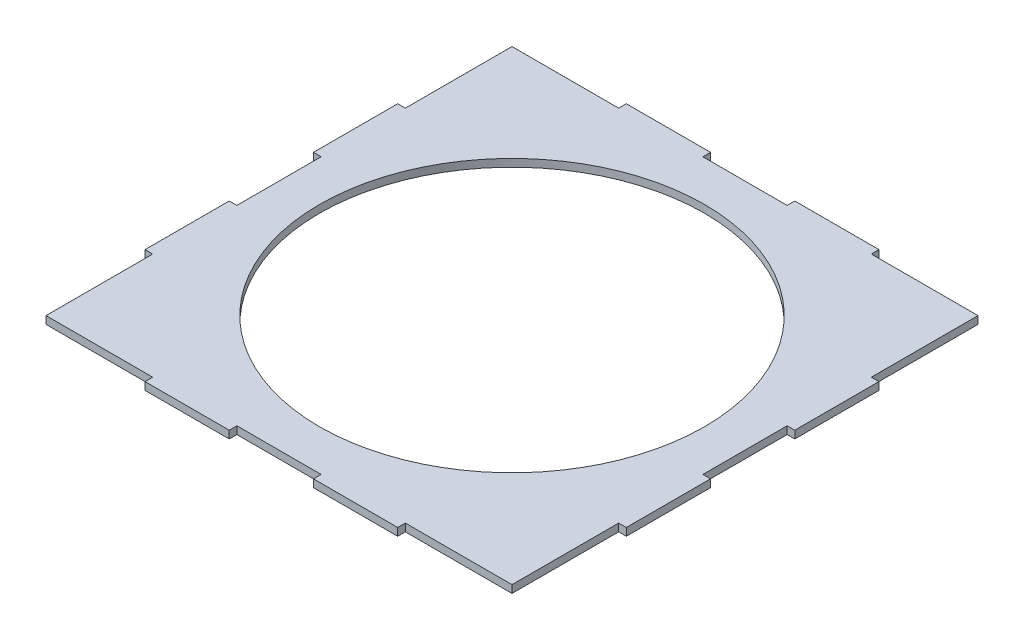
from build123d import *

# Parameters (mm, degrees)
ESQUISSE1_W             = 200
ESQUISSE1_H             = 200
BOSS_EXTRU_1_DEPTH      = 3.175
ESQUISSE2_W             = 3.175
ESQUISSE2_H             = 35
ESQUISSE2_H_2           = 47.5
ENL_V_MAT_EXTRU_1_DEPTH = 3.175
ESQUISSE4_W             = 44.325
ESQUISSE4_H             = 3.175
ESQUISSE4_W_2           = 35
ENL_V_MAT_EXTRU_3_DEPTH = 3.175
ESQUISSE3_R             = 80
ENL_V_MAT_EXTRU_2_DEPTH = 3.175


with BuildPart() as part:
    # Esquisse1 → Boss.-Extru.1 (new body)
    with BuildSketch(Plane(origin=(0, 0, 0), x_dir=(1, 0, 0), z_dir=(0, 1, 0))):
        Rectangle(ESQUISSE1_W, ESQUISSE1_H)
    extrude(amount=BOSS_EXTRU_1_DEPTH)

    # Esquisse2 → Enlèv. mat.-Extru.1 (cut)
    with BuildSketch(Plane(origin=(0, 3.175, 0), x_dir=(1, 0, 0), z_dir=(0, 1, 0))):
        with Locations((-98.4125, 0)):
            Rectangle(ESQUISSE2_W, ESQUISSE2_H)
        with Locations((-98.4125, 76.25)):
            Rectangle(ESQUISSE2_W, ESQUISSE2_H_2)
        with Locations((-98.4125, -76.25)):
            Rectangle(ESQUISSE2_W, ESQUISSE2_H_2)
    enl_v_mat_extru_1 = extrude(amount=-ENL_V_MAT_EXTRU_1_DEPTH, mode=Mode.SUBTRACT)

    # Symétrie1: Enlèv. mat.-Extru.1 across plane
    add(enl_v_mat_extru_1.mirror(Plane(origin=(0, 0, 0), x_dir=(0, 0, 1), z_dir=(1, 0, 0))), mode=Mode.SUBTRACT)

    # Esquisse4 → Enlèv. mat.-Extru.3 (cut)
    with BuildSketch(Plane(origin=(0, 3.175, 0), x_dir=(1, 0, 0), z_dir=(0, 1, 0))):
        with Locations((-74.6625, 98.4125)):
            Rectangle(ESQUISSE4_W, ESQUISSE4_H)
        with Locations((0, 98.4125)):
            Rectangle(ESQUISSE4_W_2, ESQUISSE4_H)
        with Locations((74.6625, 98.4125)):
            Rectangle(ESQUISSE4_W, ESQUISSE4_H)
    enl_v_mat_extru_3 = extrude(amount=-ENL_V_MAT_EXTRU_3_DEPTH, mode=Mode.SUBTRACT)

    # Symétrie2: Enlèv. mat.-Extru.3 across plane
    add(enl_v_mat_extru_3.mirror(Plane.XY), mode=Mode.SUBTRACT)

    # Esquisse3 → Enlèv. mat.-Extru.2 (cut)
    with BuildSketch(Plane(origin=(0, 3.175, 0), x_dir=(1, 0, 0), z_dir=(0, 1, 0))):
        Circle(ESQUISSE3_R)
    extrude(amount=-ENL_V_MAT_EXTRU_2_DEPTH, mode=Mode.SUBTRACT)


solid = part.part
